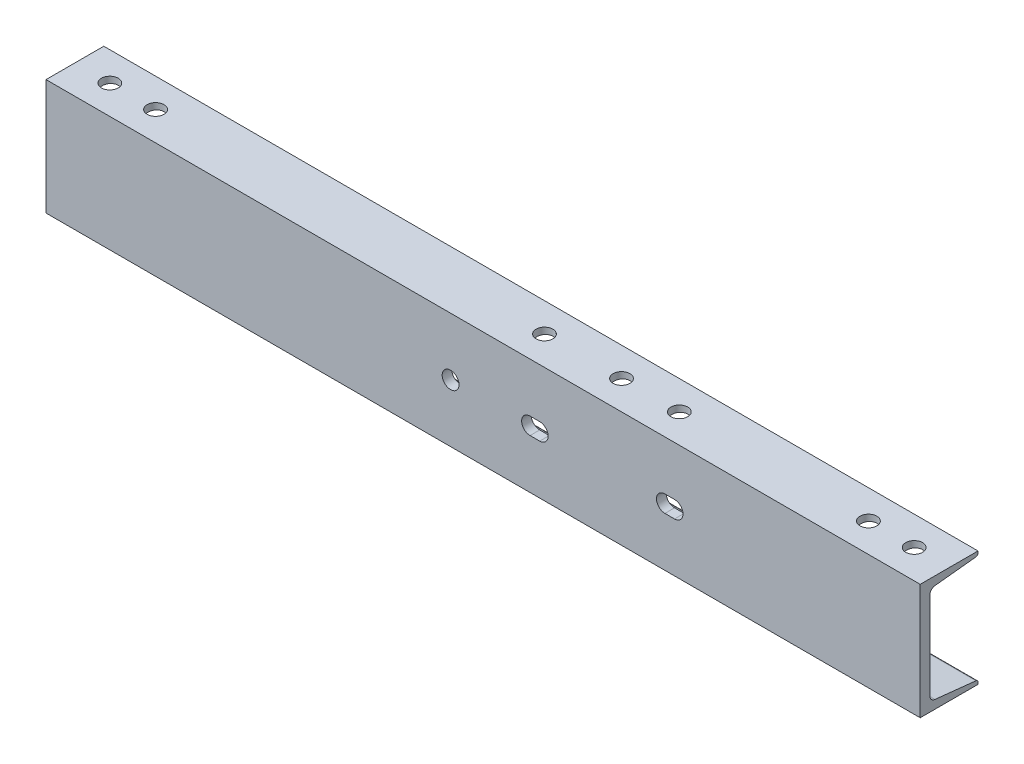
from build123d import *

# Parameters (mm, degrees)
BOSS_EXTRUDE1_DEPTH = 576.2625
SKETCH5_R           = 11.1125
CUT_EXTRUDE3_DEPTH  = 152.4
SKETCH6_R           = 11.1125
CUT_EXTRUDE4_DEPTH  = 13.7


with BuildPart() as part:
    # Sketch1 → Boss-Extrude1 (new body, symmetric)
    with BuildSketch(Plane(origin=(0, 0, 0), x_dir=(0, 0, -1), z_dir=(1, 0, 0))):
        with BuildLine():
            Line((-48.8061, -76.2), (-48.8061, 76.2))
            Line((-48.8061, 76.2), (27.3939, 76.2))
            Line((27.3939, 76.2), (27.3939, 73.710744653))
            ThreePointArc((27.3939, 73.710744653), (26.61173954, 71.672050174), (24.666685315, 70.679672107))
            Line((24.666685315, 70.679672107), (-29.288063286, 64.969518115))
            ThreePointArc((-29.288063286, 64.969518115), (-34.150698849, 62.488572947), (-36.1061, 57.391836749))
            Line((-36.1061, 57.391836749), (-36.1061, -57.391836749))
            ThreePointArc((-36.1061, -57.391836749), (-34.150698849, -62.488572947), (-29.288063286, -64.969518115))
            Line((-29.288063286, -64.969518115), (24.666685315, -70.679672107))
            ThreePointArc((24.666685315, -70.679672107), (26.61173954, -71.672050174), (27.3939, -73.710744653))
            Line((27.3939, -73.710744653), (27.3939, -76.2))
            Line((27.3939, -76.2), (-48.8061, -76.2))
        make_face()
    extrude(amount=BOSS_EXTRUDE1_DEPTH, both=True)

    # Sketch5 → Cut-Extrude3 (cut)
    with BuildSketch(Plane.XZ.offset(76.2)):
        with Locations((530.225, 10.7061)):
            Circle(SKETCH5_R)
        with Locations((469.9, 10.7061)):
            Circle(SKETCH5_R)
        with Locations((42.799, 10.7061)):
            Circle(SKETCH5_R)
        with Locations((220.599, 10.7061)):
            Circle(SKETCH5_R)
        with Locations((144.399, 10.7061)):
            Circle(SKETCH5_R)
        with Locations((-530.225, 10.7061)):
            Circle(SKETCH5_R)
        with Locations((-469.9, 10.7061)):
            Circle(SKETCH5_R)
    extrude(amount=-CUT_EXTRUDE3_DEPTH, mode=Mode.SUBTRACT)

    # Sketch6 → Cut-Extrude4 (cut, through all)
    with BuildSketch(Plane(origin=(0, 0, 36.1061), x_dir=(-1, 0, 0), z_dir=(0, 0, -1))):
        with Locations((42.8625, 0)):
            Circle(SKETCH6_R)
        with BuildLine():
            Line((-74.6125, 11.1125), (-61.9125, 11.1125))
            ThreePointArc((-61.9125, 11.1125), (-50.8, 0), (-61.9125, -11.1125))
            Line((-61.9125, -11.1125), (-74.6125, -11.1125))
            ThreePointArc((-74.6125, -11.1125), (-85.725, 0), (-74.6125, 11.1125))
        make_face()
        with BuildLine():
            Line((-239.7125, -11.1125), (-252.4125, -11.1125))
            ThreePointArc((-252.4125, -11.1125), (-263.525, 0), (-252.4125, 11.1125))
            Line((-252.4125, 11.1125), (-239.7125, 11.1125))
            ThreePointArc((-239.7125, 11.1125), (-228.6, 0), (-239.7125, -11.1125))
        make_face()
    extrude(amount=-CUT_EXTRUDE4_DEPTH, mode=Mode.SUBTRACT)


solid = part.part
